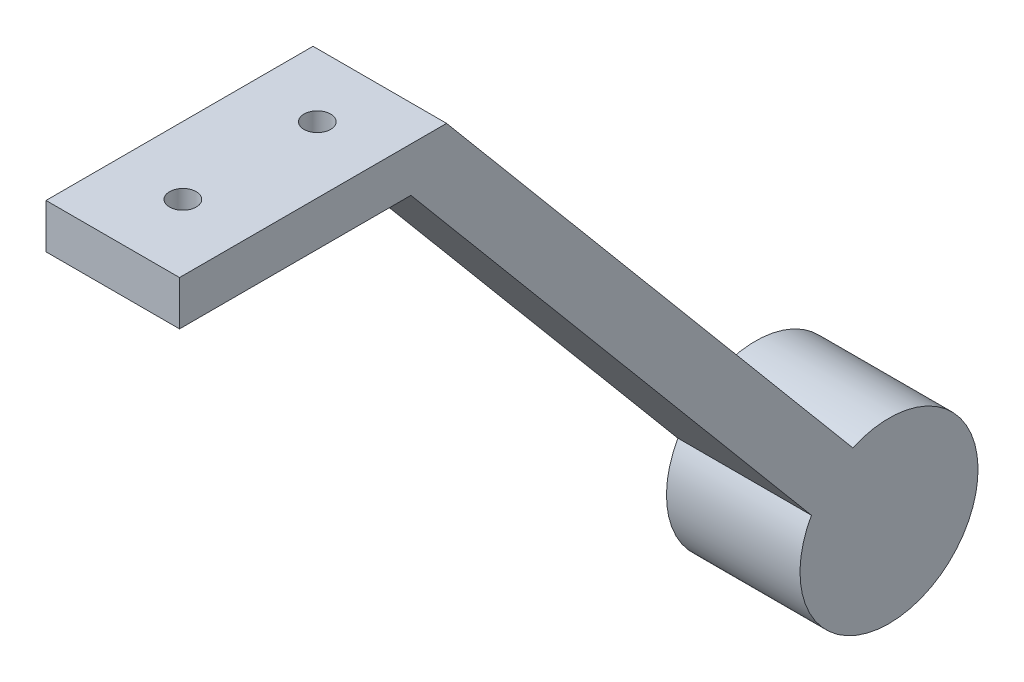
from build123d import *

# Parameters (mm, degrees)
BOSS_EXTRUDE1_DEPTH = 15
SKETCH3_R           = 1.5
CUT_EXTRUDE1_DEPTH  = 15


with BuildPart() as part:
    # Sketch2 → Boss-Extrude1 (new body)
    with BuildSketch(Plane(origin=(0, 0, 0), x_dir=(0, 0, -1), z_dir=(1, 0, 0))):
        with BuildLine():
            Line((-22.89893617, 5), (7.10106383, 5))
            Line((7.10106383, 5), (52.738984118, -49.389155461))
            ThreePointArc((52.738984118, -49.389155461), (63.539400353, -65.918178681), (48.089840145, -53.623111018))
            Line((48.089840145, -53.623111018), (3.094707467, 0))
            Line((3.094707467, 0), (-22.89893617, 0))
            Line((-22.89893617, 0), (-22.89893617, 5))
        make_face()
    extrude(amount=-BOSS_EXTRUDE1_DEPTH)

    # Sketch3 → Cut-Extrude1 (cut)
    with BuildSketch(Plane(origin=(0, 5, 0), x_dir=(1, 0, 0), z_dir=(0, 1, 0))):
        with Locations((-7.417246122, 0)):
            Circle(SKETCH3_R)
        with Locations((-7.417246122, -15.103846838)):
            Circle(SKETCH3_R)
    extrude(amount=-CUT_EXTRUDE1_DEPTH, mode=Mode.SUBTRACT)


solid = part.part
